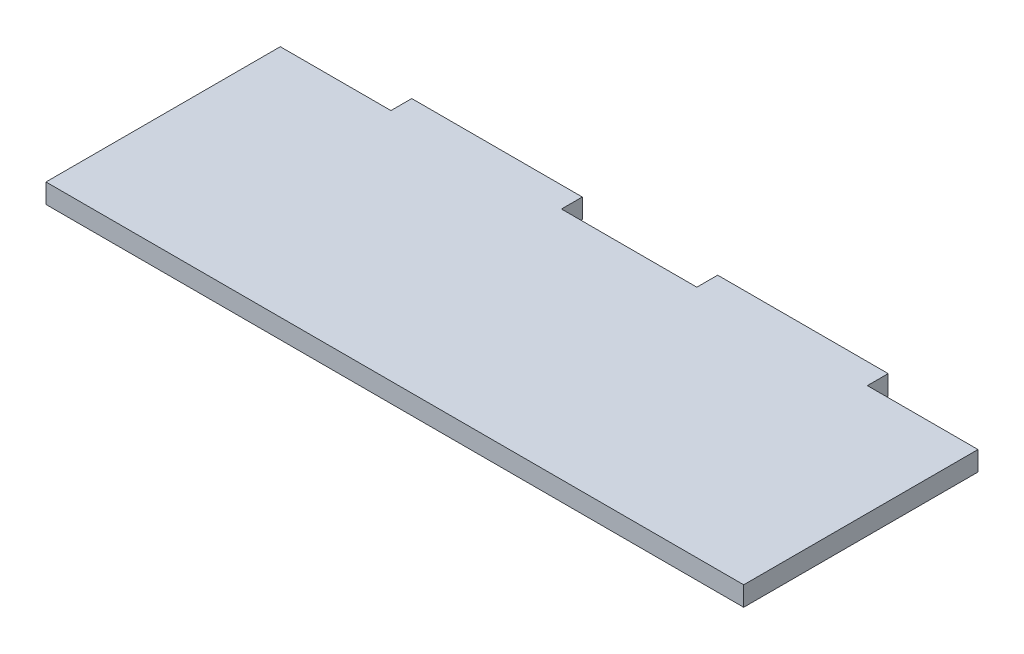
from build123d import *

# Parameters (mm, degrees)
BOSS_EXTRUDE1_DEPTH = 1.5


with BuildPart() as part:
    # Sketch1 → Boss-Extrude1 (new body)
    with BuildSketch(Plane(origin=(0, 0, 0), x_dir=(1, 0, 0), z_dir=(0, 1, 0))):
        Polygon((0, 18), (8.5, 18), (8.5, 19.6), (21.6, 19.6), (21.6, 18), (32, 18), (32, 19.6), (45.1, 19.6), (45.1, 18), (53.6, 18), (53.6, 0), (0, 0), align=None)
    extrude(amount=BOSS_EXTRUDE1_DEPTH)


solid = part.part
